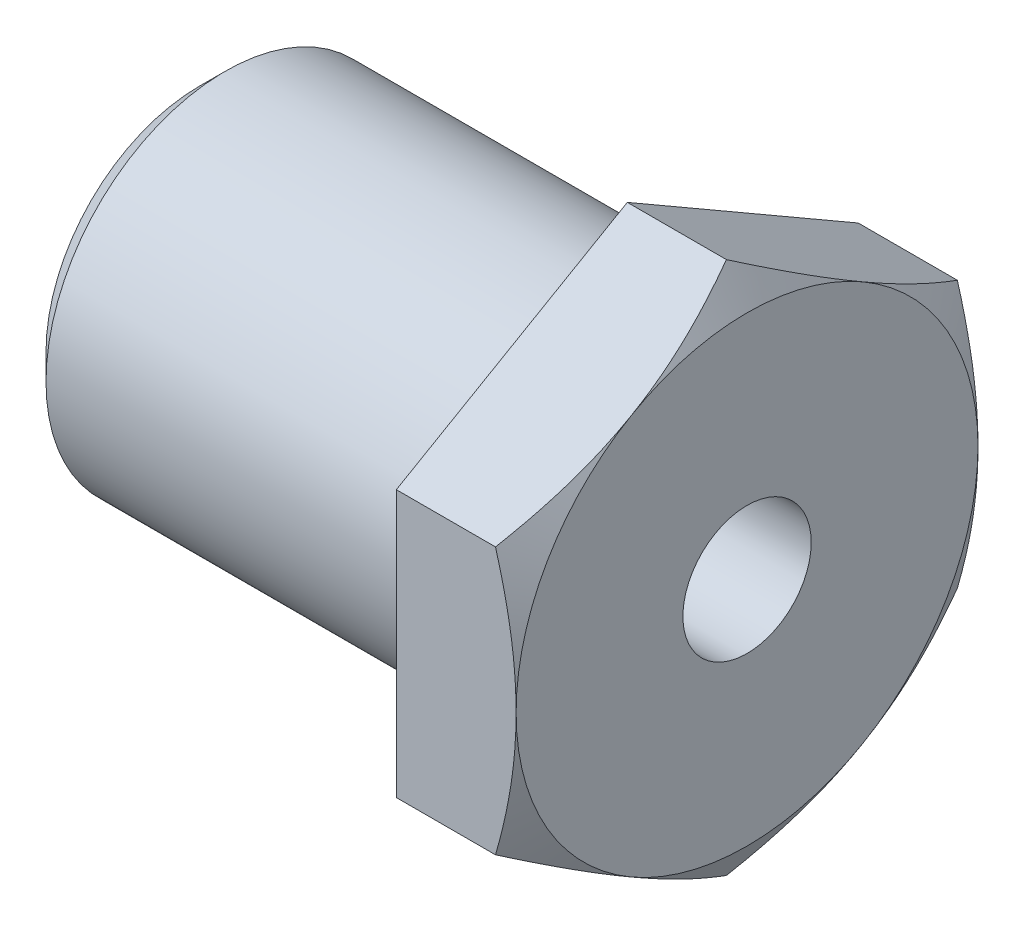
from build123d import *

# Parameters (mm, degrees)
DODANIE_WYCI_GNI_CIE1_DEPTH = 7
SZKIC2_OUTSIDE_W            = 61.616
SZKIC2_OUTSIDE_H            = 65.792
SZKIC2_OUTSIDE_R            = 13.5
WYTNIJ_WYCI_GNI_CIE1_DEPTH  = 7
WYTNIJ_WYCI_GNI_CIE1_TAPER  = 60
SZKIC3_R                    = 10.48
DODANIE_WYCI_GNI_CIE2_DEPTH = 25
SZKIC4_R                    = 7.25
WYTNIJ_WYCI_GNI_CIE2_DEPTH  = 20
SZKIC5_R                    = 3.75
WYTNIJ_WYCI_GNI_CIE3_DEPTH  = 12
SFAZOWANIE1_SIZE            = 1.5


with BuildPart() as part:
    # Szkic1 → Dodanie-wyciągnięcie1 (new body)
    with BuildSketch(Plane(origin=(0, 0, 0), x_dir=(0, 0, -1), z_dir=(1, 0, 0))):
        Polygon((13.5, 7.794228634), (0, 15.588457268), (-13.5, 7.794228634), (-13.5, -7.794228634), (0, -15.588457268), (13.5, -7.794228634), align=None)
    extrude(amount=-DODANIE_WYCI_GNI_CIE1_DEPTH)

    # Szkic2 outside → Wytnij-wyciągnięcie1 (cut)
    with BuildSketch(Plane(origin=(0, 0, 0), x_dir=(0, 0, -1), z_dir=(1, 0, 0))):
        Rectangle(SZKIC2_OUTSIDE_W, SZKIC2_OUTSIDE_H)
        Circle(SZKIC2_OUTSIDE_R, mode=Mode.SUBTRACT)
    extrude(amount=-WYTNIJ_WYCI_GNI_CIE1_DEPTH, taper=WYTNIJ_WYCI_GNI_CIE1_TAPER, mode=Mode.SUBTRACT)

    # Szkic3 → Dodanie-wyciągnięcie2 (add)
    with BuildSketch(Plane.ZY.offset(7)):
        Circle(SZKIC3_R)
    extrude(amount=DODANIE_WYCI_GNI_CIE2_DEPTH)

    # Szkic4 → Wytnij-wyciągnięcie2 (cut)
    with BuildSketch(Plane.ZY.offset(32)):
        Circle(SZKIC4_R)
    extrude(amount=-WYTNIJ_WYCI_GNI_CIE2_DEPTH, mode=Mode.SUBTRACT)

    # Szkic5 → Wytnij-wyciągnięcie3 (cut)
    with BuildSketch(Plane(origin=(0, 0, 0), x_dir=(0, 0, -1), z_dir=(1, 0, 0))):
        Circle(SZKIC5_R)
    extrude(amount=-WYTNIJ_WYCI_GNI_CIE3_DEPTH, mode=Mode.SUBTRACT)

    # Sfazowanie1
    sfazowanie1_edges = [part.edges().sort_by_distance(p)[0] for p in [
        (-32, 0, -10.48),
    ]]
    chamfer(sfazowanie1_edges, length=SFAZOWANIE1_SIZE)

    # Szkic6 → Wycięcie-obrót1 (revolve, cut)
    with BuildSketch(Plane.XY):
        with BuildLine():
            Line((-9, 10), (-9, 11.5))
            Line((-9, 11.5), (-7, 11.5))
            Line((-7, 11.5), (-7, 10))
            ThreePointArc((-7, 10), (-8, 9), (-9, 10))
        make_face()
    revolve(axis=Axis((0, 0, 0), (-1, 0, 0)), mode=Mode.SUBTRACT)


solid = part.part
